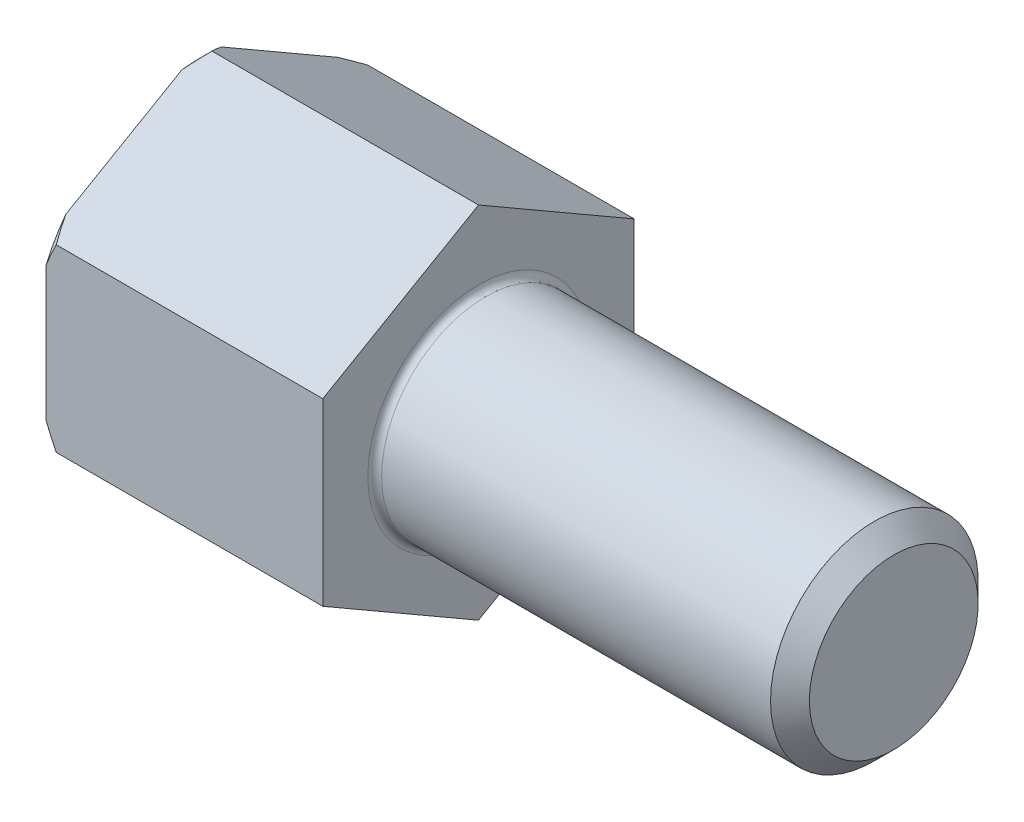
from build123d import *

# Parameters (mm, degrees)
FILLET1_R                 = 0.1
SKETCH3_OUTSIDE_W         = 12.048
SKETCH3_OUTSIDE_H         = 12.048
HEX_2_DEPTH               = 11
M3X0_5_TAPPED_HOLE1_D     = 2.5
M3X0_5_TAPPED_HOLE1_DEPTH = 3.5
M3X0_5_TAPPED_HOLE1_TIP   = 0.751075774


with BuildPart() as part:
    # BodySke → Base-Revolve (revolve)
    with BuildSketch(Plane.XY):
        Polygon((0, 0), (0, 2.45), (0.3, 2.75), (4, 2.75), (4, 1.5), (9.7195, 1.5), (10, 1.2195), (10, 0), align=None)
    revolve(axis=Axis((-31.75, 0, 0), (1, 0, 0)))

    # Fillet1
    fillet1_edges = [part.edges().sort_by_distance(p)[0] for p in [
        (4, -1.5, 0),
    ]]
    fillet(fillet1_edges, radius=FILLET1_R)

    # Sketch3 outside → Hex 2 (cut, through all)
    with BuildSketch(Plane(origin=(0, 0, 0), x_dir=(0, 0.5, 0.866025404), z_dir=(-1, 0, 0))):
        Rectangle(SKETCH3_OUTSIDE_W, SKETCH3_OUTSIDE_H)
        Polygon((1.299038106, 2.25), (-1.299038106, 2.25), (-2.598076211, 0), (-1.299038106, -2.25), (1.299038106, -2.25), (2.598076211, 0), align=None, mode=Mode.SUBTRACT)
    extrude(amount=-HEX_2_DEPTH, mode=Mode.SUBTRACT)

    # M3x0.5 Tapped Hole1
    with Locations(Plane(origin=(0, 0, 0), x_dir=(0, 0, -1), z_dir=(-1, 0, 0))):
        with Locations((0, 0)):
            Hole(M3X0_5_TAPPED_HOLE1_D / 2, depth=M3X0_5_TAPPED_HOLE1_DEPTH)
            with Locations((0, 0, -(M3X0_5_TAPPED_HOLE1_DEPTH + M3X0_5_TAPPED_HOLE1_TIP / 2))):  # 118° drill point
                Cone(0, M3X0_5_TAPPED_HOLE1_D / 2, M3X0_5_TAPPED_HOLE1_TIP, mode=Mode.SUBTRACT)


solid = part.part
